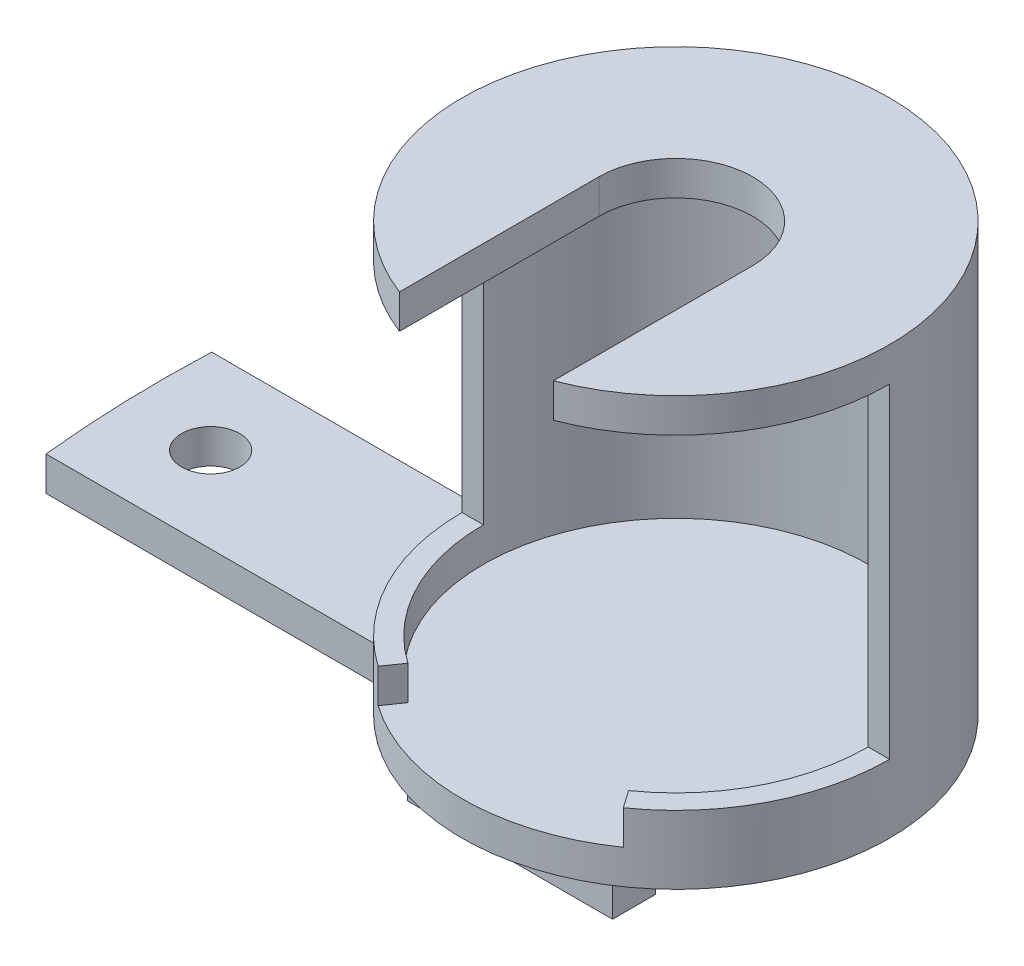
from build123d import *

# Parameters (mm, degrees)
CROQUIS1_R              = 12.5
CROQUIS1_R_2            = 11.25
SALIENTE_EXTRUIR1_DEPTH = 21
CORTAR_EXTRUIR1_DEPTH   = 19
CROQUIS3_R              = 12.5
SALIENTE_EXTRUIR2_DEPTH = 2
SALIENTE_EXTRUIR3_DEPTH = 2
CORTAR_EXTRUIR2_DEPTH   = 2
CROQUIS6_R              = 1.7
SALIENTE_EXTRUIR4_DEPTH = 2
CROQUIS8_W              = 12
CROQUIS8_H              = 2.5
SALIENTE_EXTRUIR5_DEPTH = 2.5


with BuildPart() as part:
    # Croquis1 → Saliente-Extruir1 (new body)
    with BuildSketch(Plane(origin=(0, 0, 0), x_dir=(1, 0, 0), z_dir=(0, 1, 0))):
        Circle(CROQUIS1_R)
        Circle(CROQUIS1_R_2, mode=Mode.SUBTRACT)
    extrude(amount=SALIENTE_EXTRUIR1_DEPTH)

    # Croquis2 → Cortar-Extruir1 (cut)
    with BuildSketch(Plane(origin=(0, 21, 0), x_dir=(1, 0, 0), z_dir=(0, 1, 0))):
        with BuildLine():
            Line((-12.5, 0), (12.5, 0))
            ThreePointArc((12.5, 0), (0, -12.5), (-12.5, 0))
        make_face()
    extrude(amount=-CORTAR_EXTRUIR1_DEPTH, mode=Mode.SUBTRACT)

    # Croquis3 → Saliente-Extruir2 (add)
    with BuildSketch(Plane.XZ):
        Circle(CROQUIS3_R)
    extrude(amount=SALIENTE_EXTRUIR2_DEPTH)

    # Croquis4 → Saliente-Extruir3 (add)
    with BuildSketch(Plane(origin=(0, 21, 0), x_dir=(1, 0, 0), z_dir=(0, 1, 0))):
        with BuildLine():
            Line((-4.5, 0), (-4.5, -11.66190379))
            ThreePointArc((-4.5, -11.66190379), (0, 12.5), (4.5, -11.66190379))
            Line((4.5, -11.66190379), (4.5, 0))
            ThreePointArc((4.5, 0), (0, 4.5), (-4.5, 0))
        make_face()
    extrude(amount=SALIENTE_EXTRUIR3_DEPTH)

    # Croquis5 → Cortar-Extruir2 (cut)
    with BuildSketch(Plane(origin=(0, 2, 0), x_dir=(1, 0, 0), z_dir=(0, 1, 0))):
        with BuildLine():
            Line((0, 0), (-7.169705454, -10.239400554))
            ThreePointArc((-7.169705454, -10.239400554), (0, -12.5), (7.169705454, -10.239400554))
            Line((7.169705454, -10.239400554), (0, 0))
        make_face()
    extrude(amount=-CORTAR_EXTRUIR2_DEPTH, mode=Mode.SUBTRACT)

    # Croquis6 → Saliente-Extruir4 (add)
    with BuildSketch(Plane(origin=(0, 0, 0), x_dir=(1, 0, 0), z_dir=(0, 1, 0))):
        with BuildLine():
            Line((-29.628729703, -7.2), (-10.218121158, -7.2))
            ThreePointArc((-10.218121158, -7.2), (-12.265620132, -2.409266026), (-12.182364303, 2.8))
            Line((-12.182364303, 2.8), (-29.943977582, 2.8))
            ThreePointArc((-29.943977582, 2.8), (-29.965242476, -2.205639433), (-29.628729703, -7.2))
        make_face()
        with Locations((-25, -2.2)):
            Circle(CROQUIS6_R, mode=Mode.SUBTRACT)
    extrude(amount=-SALIENTE_EXTRUIR4_DEPTH)

    # Croquis8 → Saliente-Extruir5 (add)
    with BuildSketch(Plane.XZ.offset(2)):
        with Locations((0, 8.45)):
            Rectangle(CROQUIS8_W, CROQUIS8_H)
        with Locations((0, -4.05)):
            Rectangle(CROQUIS8_W, CROQUIS8_H)
    extrude(amount=SALIENTE_EXTRUIR5_DEPTH)


solid = part.part
